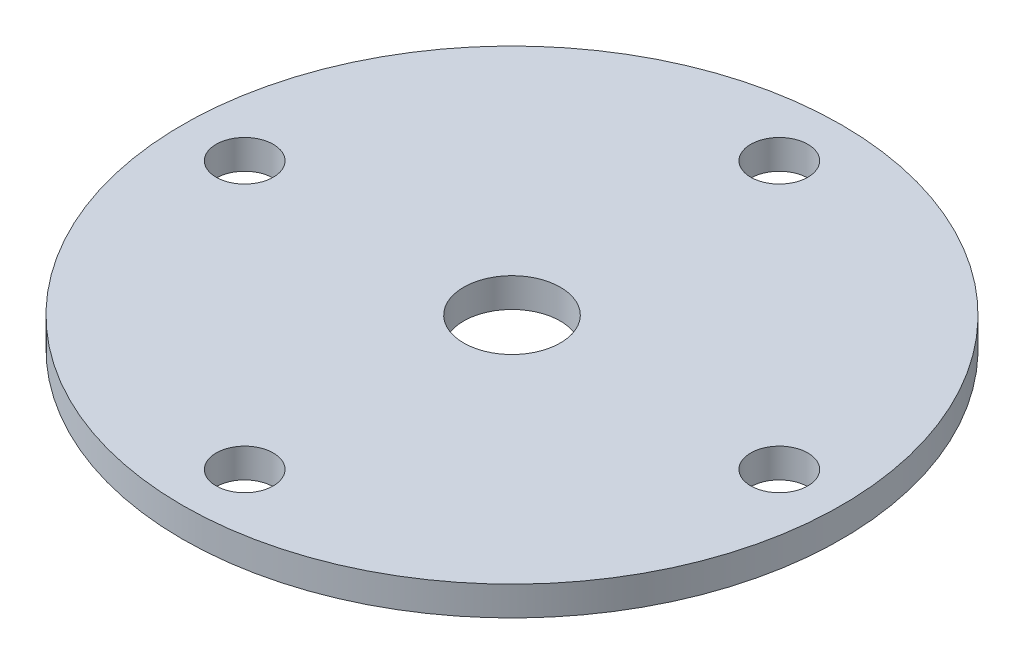
from build123d import *

# Parameters (mm, degrees)
SKETCH1_R           = 33.75
SKETCH1_R_2         = 4.95
SKETCH1_R_3         = 2.925
BOSS_EXTRUDE1_DEPTH = 3


with BuildPart() as part:
    # Sketch1 → Boss-Extrude1 (new body)
    with BuildSketch(Plane(origin=(0, 0, 0), x_dir=(1, 0, 0), z_dir=(0, 1, 0))):
        Circle(SKETCH1_R)
        Circle(SKETCH1_R_2, mode=Mode.SUBTRACT)
        with Locations((0, 27.375)):
            Circle(SKETCH1_R_3, mode=Mode.SUBTRACT)
        with Locations((27.375, 0)):
            Circle(SKETCH1_R_3, mode=Mode.SUBTRACT)
        with Locations((0, -27.375)):
            Circle(SKETCH1_R_3, mode=Mode.SUBTRACT)
        with Locations((-27.375, 0)):
            Circle(SKETCH1_R_3, mode=Mode.SUBTRACT)
    extrude(amount=BOSS_EXTRUDE1_DEPTH)


solid = part.part
